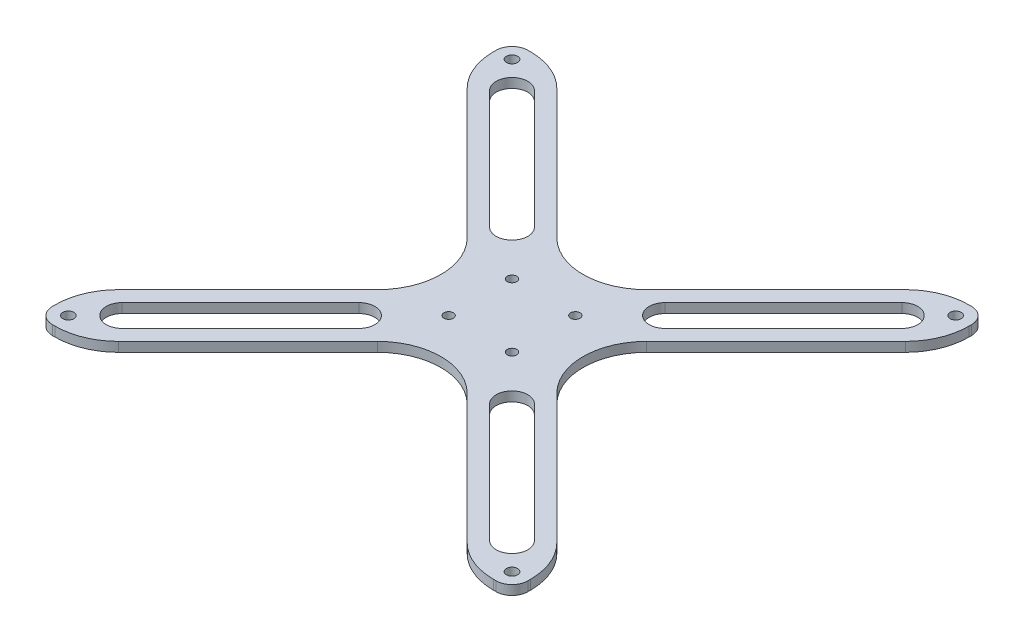
from build123d import *

# Parameters (mm, degrees)
SKETCH3_W           = 150
SKETCH3_H           = 150
SKETCH3_R           = 1.75
SKETCH3_R_2         = 1.5
BOSS_EXTRUDE2_DEPTH = 3
CUT_EXTRUDE2_REACH  = 5
FILLET2_R           = 5
FILLET3_R           = 20


with BuildPart() as part:
    # Sketch3 → Boss-Extrude2 (new body)
    with BuildSketch(Plane(origin=(0, 0, 0), x_dir=(1, 0, 0), z_dir=(0, 1, 0))):
        Rectangle(SKETCH3_W, SKETCH3_H)
        with Locations((-70, 70)):
            Circle(SKETCH3_R, mode=Mode.SUBTRACT)
        with Locations((70, -70)):
            Circle(SKETCH3_R, mode=Mode.SUBTRACT)
        with Locations((-70, -70)):
            Circle(SKETCH3_R, mode=Mode.SUBTRACT)
        with Locations((70, 70)):
            Circle(SKETCH3_R, mode=Mode.SUBTRACT)
        with Locations((-10, 10)):
            Circle(SKETCH3_R_2, mode=Mode.SUBTRACT)
        with Locations((10, -10)):
            Circle(SKETCH3_R_2, mode=Mode.SUBTRACT)
        with Locations((-10, -10)):
            Circle(SKETCH3_R_2, mode=Mode.SUBTRACT)
        with Locations((10, 10)):
            Circle(SKETCH3_R_2, mode=Mode.SUBTRACT)
    extrude(amount=BOSS_EXTRUDE2_DEPTH)

    # Sketch4 → Cut-Extrude2 (cut, up to next)
    with BuildSketch(Plane(origin=(0, 3, 0), x_dir=(1, 0, 0), z_dir=(0, 1, 0)), mode=Mode.PRIVATE) as cut_extrude2_sk1:
        with BuildLine():
            Line((-27.67766953, 20.606601718), (-65.050252532, 57.97918472))
            ThreePointArc((-65.050252532, 57.97918472), (-65.050252532, 65.050252532), (-57.97918472, 65.050252532))
            Line((-57.97918472, 65.050252532), (-20.606601718, 27.67766953))
            ThreePointArc((-20.606601718, 27.67766953), (-20.606601718, 20.606601718), (-27.67766953, 20.606601718))
        make_face()
    cut_extrude2_tool1 = extrude(cut_extrude2_sk1.sketch, amount=-CUT_EXTRUDE2_REACH, mode=Mode.PRIVATE) & part.part
    add(cut_extrude2_tool1.solids().sort_by_distance((-42.828427, 3, -42.828427))[0], mode=Mode.SUBTRACT)
    # Sketch4 → Cut-Extrude2 (cut, up to next)
    with BuildSketch(Plane(origin=(0, 3, 0), x_dir=(1, 0, 0), z_dir=(0, 1, 0)), mode=Mode.PRIVATE) as cut_extrude2_sk2:
        Polygon((-75, 60.857864376), (-14.142135624, 0), (-75, -60.857864376), align=None)
    cut_extrude2_tool2 = extrude(cut_extrude2_sk2.sketch, amount=-CUT_EXTRUDE2_REACH, mode=Mode.PRIVATE) & part.part
    add(cut_extrude2_tool2.solids().sort_by_distance((-54.714045, 3, 0))[0], mode=Mode.SUBTRACT)
    # Sketch4 → Cut-Extrude2 (cut, up to next)
    with BuildSketch(Plane(origin=(0, 3, 0), x_dir=(1, 0, 0), z_dir=(0, 1, 0)), mode=Mode.PRIVATE) as cut_extrude2_sk3:
        with BuildLine():
            Line((27.67766953, 20.606601718), (65.050252532, 57.97918472))
            ThreePointArc((65.050252532, 57.97918472), (65.050252532, 65.050252532), (57.97918472, 65.050252532))
            Line((57.97918472, 65.050252532), (20.606601718, 27.67766953))
            ThreePointArc((20.606601718, 27.67766953), (20.606601718, 20.606601718), (27.67766953, 20.606601718))
        make_face()
    cut_extrude2_tool3 = extrude(cut_extrude2_sk3.sketch, amount=-CUT_EXTRUDE2_REACH, mode=Mode.PRIVATE) & part.part
    add(cut_extrude2_tool3.solids().sort_by_distance((42.828427, 3, -42.828427))[0], mode=Mode.SUBTRACT)
    # Sketch4 → Cut-Extrude2 (cut, up to next)
    with BuildSketch(Plane(origin=(0, 3, 0), x_dir=(1, 0, 0), z_dir=(0, 1, 0)), mode=Mode.PRIVATE) as cut_extrude2_sk4:
        with BuildLine():
            Line((27.67766953, -20.606601718), (65.050252532, -57.97918472))
            ThreePointArc((65.050252532, -57.97918472), (65.050252532, -65.050252532), (57.97918472, -65.050252532))
            Line((57.97918472, -65.050252532), (20.606601718, -27.67766953))
            ThreePointArc((20.606601718, -27.67766953), (20.606601718, -20.606601718), (27.67766953, -20.606601718))
        make_face()
    cut_extrude2_tool4 = extrude(cut_extrude2_sk4.sketch, amount=-CUT_EXTRUDE2_REACH, mode=Mode.PRIVATE) & part.part
    add(cut_extrude2_tool4.solids().sort_by_distance((42.828427, 3, 42.828427))[0], mode=Mode.SUBTRACT)
    # Sketch4 → Cut-Extrude2 (cut, up to next)
    with BuildSketch(Plane(origin=(0, 3, 0), x_dir=(1, 0, 0), z_dir=(0, 1, 0)), mode=Mode.PRIVATE) as cut_extrude2_sk5:
        with BuildLine():
            Line((-27.67766953, -20.606601718), (-65.050252532, -57.97918472))
            ThreePointArc((-65.050252532, -57.97918472), (-65.050252532, -65.050252532), (-57.97918472, -65.050252532))
            Line((-57.97918472, -65.050252532), (-20.606601718, -27.67766953))
            ThreePointArc((-20.606601718, -27.67766953), (-20.606601718, -20.606601718), (-27.67766953, -20.606601718))
        make_face()
    cut_extrude2_tool5 = extrude(cut_extrude2_sk5.sketch, amount=-CUT_EXTRUDE2_REACH, mode=Mode.PRIVATE) & part.part
    add(cut_extrude2_tool5.solids().sort_by_distance((-42.828427, 3, 42.828427))[0], mode=Mode.SUBTRACT)
    # Sketch4 → Cut-Extrude2 (cut, up to next)
    with BuildSketch(Plane(origin=(0, 3, 0), x_dir=(1, 0, 0), z_dir=(0, 1, 0)), mode=Mode.PRIVATE) as cut_extrude2_sk6:
        Polygon((75, 60.857864376), (14.142135624, 0), (75, -60.857864376), align=None)
    cut_extrude2_tool6 = extrude(cut_extrude2_sk6.sketch, amount=-CUT_EXTRUDE2_REACH, mode=Mode.PRIVATE) & part.part
    add(cut_extrude2_tool6.solids().sort_by_distance((54.714045, 3, 0))[0], mode=Mode.SUBTRACT)
    # Sketch4 → Cut-Extrude2 (cut, up to next)
    with BuildSketch(Plane(origin=(0, 3, 0), x_dir=(1, 0, 0), z_dir=(0, 1, 0)), mode=Mode.PRIVATE) as cut_extrude2_sk7:
        Polygon((-60.857864376, -75), (60.857864376, -75), (0, -14.142135624), align=None)
    cut_extrude2_tool7 = extrude(cut_extrude2_sk7.sketch, amount=-CUT_EXTRUDE2_REACH, mode=Mode.PRIVATE) & part.part
    add(cut_extrude2_tool7.solids().sort_by_distance((0, 3, 54.714045))[0], mode=Mode.SUBTRACT)
    # Sketch4 → Cut-Extrude2 (cut, up to next)
    with BuildSketch(Plane(origin=(0, 3, 0), x_dir=(1, 0, 0), z_dir=(0, 1, 0)), mode=Mode.PRIVATE) as cut_extrude2_sk8:
        Polygon((-60.857864376, 75), (0, 14.142135624), (60.857864376, 75), align=None)
    cut_extrude2_tool8 = extrude(cut_extrude2_sk8.sketch, amount=-CUT_EXTRUDE2_REACH, mode=Mode.PRIVATE) & part.part
    add(cut_extrude2_tool8.solids().sort_by_distance((0, 3, -54.714045))[0], mode=Mode.SUBTRACT)

    # Fillet2
    fillet2_edges = [part.edges().sort_by_distance(p)[0] for p in [
        (75, 1.5, 75),
        (-75, 1.5, 75),
        (-75, 1.5, -75),
        (75, 1.5, -75),
    ]]
    fillet(fillet2_edges, radius=FILLET2_R)

    # Fillet3
    fillet3_edges = [part.edges().sort_by_distance(p)[0] for p in [
        (75, 1.5, -60.857864376),
        (75, 1.5, 60.857864376),
        (14.142135624, 1.5, 0),
        (-60.857864376, 1.5, 75),
        (0, 1.5, 14.142135624),
        (60.857864376, 1.5, 75),
        (-75, 1.5, 60.857864376),
        (-75, 1.5, -60.857864376),
        (-14.142135624, 1.5, 0),
        (-60.857864376, 1.5, -75),
        (60.857864376, 1.5, -75),
        (0, 1.5, -14.142135624),
    ]]
    fillet(fillet3_edges, radius=FILLET3_R)


solid = part.part
